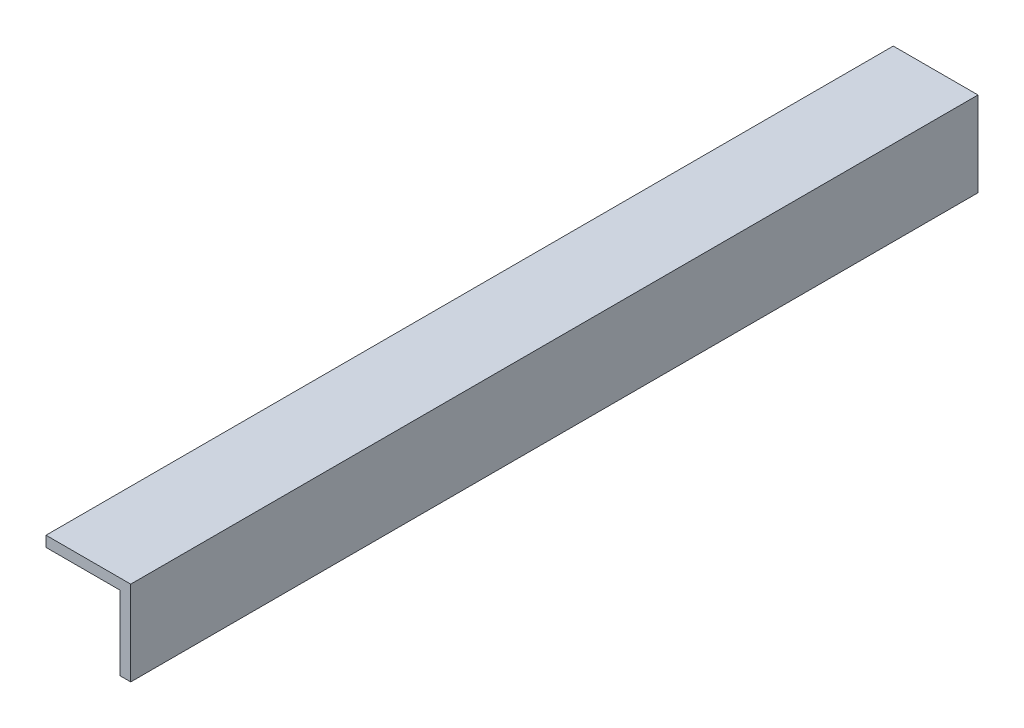
from build123d import *

# Parameters (mm, degrees)
BOSS_EXTRUDE1_DEPTH = 254


with BuildPart() as part:
    # Sketch1 → Boss-Extrude1 (new body)
    with BuildSketch(Plane.XY):
        Polygon((1.914135642, 12.7), (1.914135642, -12.7), (-1.260864358, -12.7), (-1.260864358, 9.525), (-23.485864358, 9.525), (-23.485864358, 12.7), align=None)
    extrude(amount=BOSS_EXTRUDE1_DEPTH)


solid = part.part
